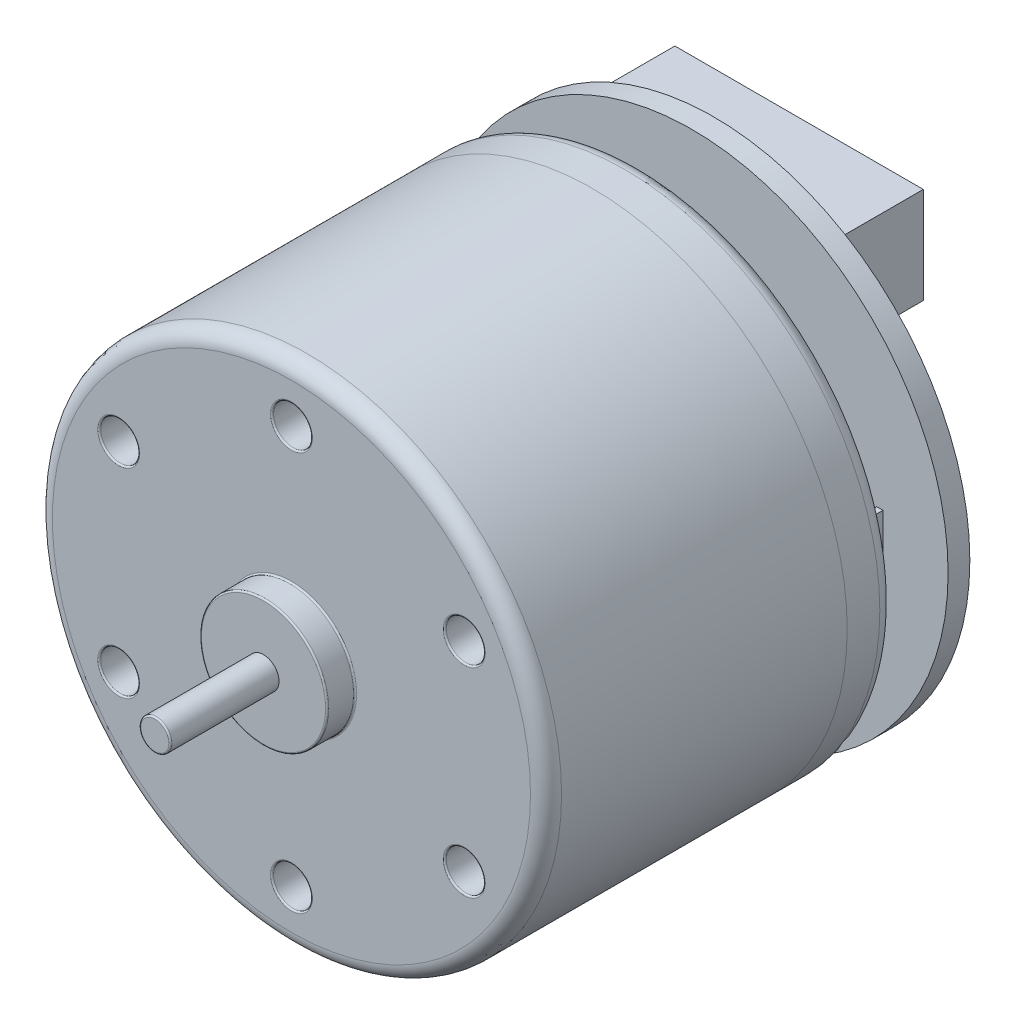
from build123d import *

# Parameters (mm, degrees)
SKETCH1_R                = 16.4
BOSS_EXTRUDE1_DEPTH      = 19.4
SKETCH3_R                = 16.5
BOSS_EXTRUDE3_DEPTH      = 1.4
BOSS_EXTRUDE4_DEPTH      = 4.6
BOSS_EXTRUDE4_DEPTH_BACK = 1.1
SKETCH4_W                = 0.4
SKETCH4_H                = 2.8
SKETCH1_3_R              = 4.1
BOSS_EXTRUDE5_DEPTH      = 1.8
BOSS_EXTRUDE6_DEPTH      = 8.8
BOSS_EXTRUDE6_DEPTH_BACK = 32
SKETCH1_4_R              = 1
SKETCH1_5_R              = 1.25
CUT_EXTRUDE1_DEPTH       = 2
BOSS_EXTRUDE7_START      = 4.2
SKETCH5_R                = 6.7
SKETCH5_R_2              = 1
BOSS_EXTRUDE7_DEPTH      = 4.2
SKETCH6_W                = 16
SKETCH6_H                = 6.2
BOSS_EXTRUDE8_DEPTH      = 5.5
SKETCH2_R                = 16.4
BOSS_EXTRUDE9_DEPTH      = 3.1
FILLET1_R                = 0.1
FILLET2_R                = 1
FILLET3_R                = 1


with BuildPart() as part:
    # Sketch1 → Boss-Extrude1 (new body)
    with BuildSketch(Plane.XY):
        Circle(SKETCH1_R)
    extrude(amount=-BOSS_EXTRUDE1_DEPTH)

    # Sketch1_3 → Boss-Extrude5 (add)
    with BuildSketch(Plane.XY):
        Circle(SKETCH1_3_R)
    extrude(amount=BOSS_EXTRUDE5_DEPTH)



with BuildPart() as body_2:
    # Sketch3 → Boss-Extrude3 (new body)
    with BuildSketch(Plane.XY.offset(-27.2)):
        Circle(SKETCH3_R)
    extrude(amount=BOSS_EXTRUDE3_DEPTH)

    # Sketch4 → Boss-Extrude4 (add, two sides: drawn at the far end of the back side and taken through both)
    with BuildSketch(Plane.XY.offset(-27.2).offset(-BOSS_EXTRUDE4_DEPTH_BACK)):
        with Locations((12.1, 0)):
            Rectangle(SKETCH4_W, SKETCH4_H)
        with Locations((-12.1, 0)):
            Rectangle(SKETCH4_W, SKETCH4_H)
    extrude(amount=BOSS_EXTRUDE4_DEPTH + BOSS_EXTRUDE4_DEPTH_BACK)


with BuildPart() as part_1:
    add(part.part)

    add(body_2.part)  # Boss-Extrude6 merges body 2
    # Sketch1_4 → Boss-Extrude6 (add, two sides: drawn at the far end of the back side and taken through both)
    with BuildSketch(Plane.XY.offset(-BOSS_EXTRUDE6_DEPTH_BACK)):
        Circle(SKETCH1_4_R)
    extrude(amount=BOSS_EXTRUDE6_DEPTH + BOSS_EXTRUDE6_DEPTH_BACK)

    # Sketch1_5 → Cut-Extrude1 (cut)
    with BuildSketch(Plane.XY):
        with Locations((0, 12.85)):
            Circle(SKETCH1_5_R)
        with Locations((-11.128426439, 6.425)):
            Circle(SKETCH1_5_R)
        with Locations((11.128426439, 6.425)):
            Circle(SKETCH1_5_R)
        with Locations((11.128426439, -6.425)):
            Circle(SKETCH1_5_R)
        with Locations((0, -12.85)):
            Circle(SKETCH1_5_R)
        with Locations((-11.128426439, -6.425)):
            Circle(SKETCH1_5_R)
    extrude(amount=-CUT_EXTRUDE1_DEPTH, mode=Mode.SUBTRACT)

    # Sketch5 → Boss-Extrude7 (add)
    with BuildSketch(Plane.XY.offset(-33.4).offset(BOSS_EXTRUDE7_START)):
        Circle(SKETCH5_R)
        Circle(SKETCH5_R_2, mode=Mode.SUBTRACT)
    extrude(amount=-BOSS_EXTRUDE7_DEPTH)

    # Sketch6 → Boss-Extrude8 (add)
    with BuildSketch(Plane.XY.offset(-27.2)):
        with Locations((0, 10.6)):
            Rectangle(SKETCH6_W, SKETCH6_H)
    extrude(amount=-BOSS_EXTRUDE8_DEPTH)

    # Fillet1
    fillet1_edges = [part_1.edges().sort_by_distance(p)[0] for p in [
        (-6.7, 0, -29.2),
        (-6.7, 0, -33.4),
        (-4.1, 0, 0),
        (-4.1, 0, 1.8),
        (9.878426439, 6.425, 0),
        (9.878426439, -6.425, 0),
        (-1.25, -12.85, 0),
        (-12.378426439, -6.425, 0),
        (-12.378426439, 6.425, 0),
        (-1.25, 12.85, 0),
        (-1, 0, 8.8),
    ]]
    fillet(fillet1_edges, radius=FILLET1_R)

    # Fillet2
    fillet2_edges = [part_1.edges().sort_by_distance(p)[0] for p in [
        (-12.1, -1.4, -28.3),
        (-12.1, 1.4, -28.3),
        (12.1, -1.4, -28.3),
        (12.1, 1.4, -28.3),
        (-16.4, 0, 0),
    ]]
    fillet(fillet2_edges, radius=FILLET2_R)


with BuildPart() as body_2_2:
    # Sketch2 → Boss-Extrude9 (new body)
    with BuildSketch(Plane(origin=(0, 0, -19.4), x_dir=(-1, 0, 0), z_dir=(0, 0, -1))):
        Circle(SKETCH2_R)
    extrude(amount=BOSS_EXTRUDE9_DEPTH)

    # Fillet3
    fillet3_edges = [body_2_2.edges().sort_by_distance(p)[0] for p in [
        (16.4, 0, -22.5),
    ]]
    fillet(fillet3_edges, radius=FILLET3_R)


solid = Compound([part_1.part, body_2_2.part])
